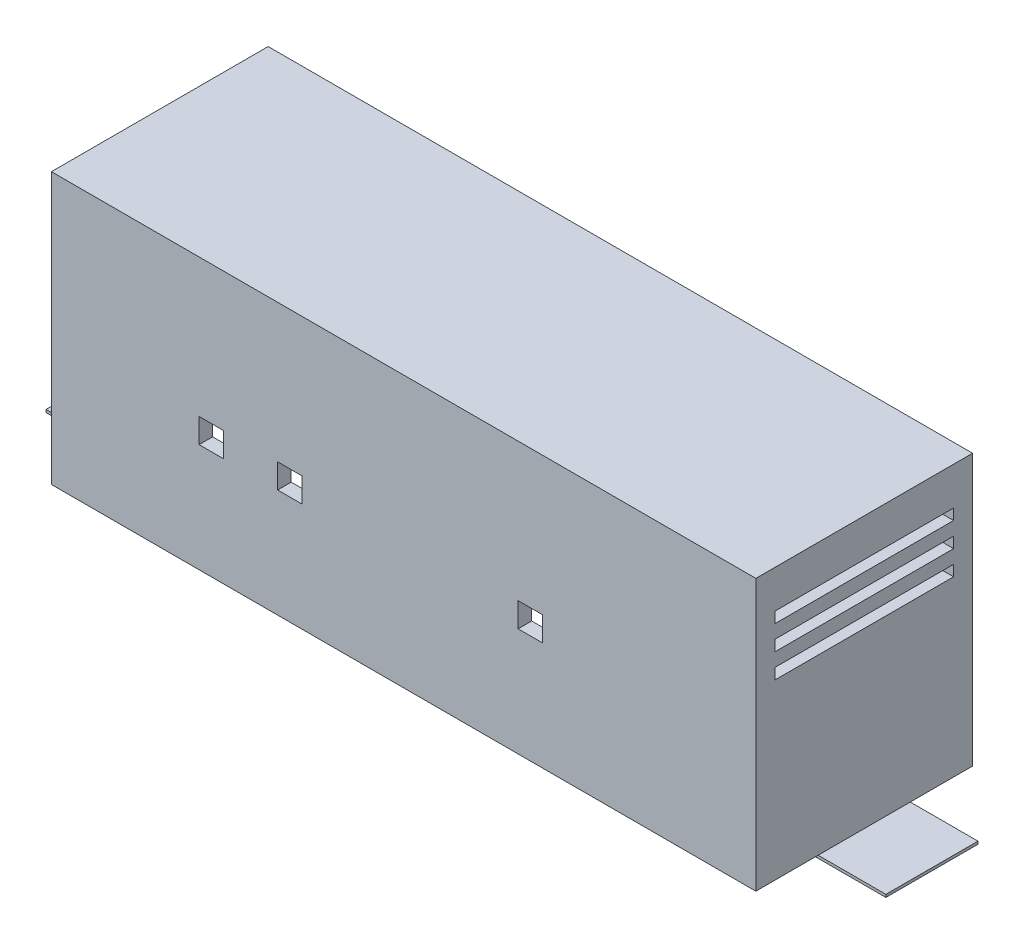
from build123d import *

# Parameters (mm, degrees)
SKETCH1_W                 = 260
SKETCH1_H                 = 80
BOSS_EXTRUDE1_DEPTH       = 100
SKETCH2_W                 = 250
SKETCH2_H                 = 70.000000188
INSIDE_DEPTH              = 90
SKETCH8_W                 = 9
SKETCH8_H                 = 9
WIRE_HOLES_DEPTH          = 23
SKETCH12_W                = 66
SKETCH12_H                = 4
VENTALATION_DEPTH         = 15
SKETCH14_W                = 66
SKETCH14_H                = 4
VENTALATION_2_DEPTH       = 10
SKETCH16_W                = 66
SKETCH16_H                = 4
VENTALATION_3_DEPTH       = 10
SKETCH20_W                = 34
SKETCH20_H                = 30
COMMAND_STRIP_FRONT_DEPTH = 1
SKETCH21_W                = 30
SKETCH21_H                = 34.000000188
COMMAND_STRIP_RIGHT_DEPTH = 1
SKETCH22_W                = 30
SKETCH22_H                = 34.000000188
BOSS_EXTRUDE4_DEPTH       = 1


with BuildPart() as part:
    # Sketch1 → Boss-Extrude1 (new body)
    with BuildSketch(Plane(origin=(0, 0, 0), x_dir=(1, 0, 0), z_dir=(0, 1, 0))):
        Rectangle(SKETCH1_W, SKETCH1_H)
    extrude(amount=BOSS_EXTRUDE1_DEPTH)

    # Sketch2 → inside (cut)
    with BuildSketch(Plane.XZ):
        Rectangle(SKETCH2_W, SKETCH2_H)
    extrude(amount=-INSIDE_DEPTH, mode=Mode.SUBTRACT)

    # Sketch8 → Wire holes (cut)
    with BuildSketch(Plane.XY.offset(40)):
        with Locations((-71, 44.5)):
            Rectangle(SKETCH8_W, SKETCH8_H)
        with Locations((-42, 44.5)):
            Rectangle(SKETCH8_W, SKETCH8_H)
        with Locations((46.75, 44.5)):
            Rectangle(SKETCH8_W, SKETCH8_H)
    extrude(amount=-WIRE_HOLES_DEPTH, mode=Mode.SUBTRACT)

    # Sketch12 → Ventalation (cut)
    with BuildSketch(Plane(origin=(130, 0, 0), x_dir=(0, 0, -1), z_dir=(1, 0, 0))):
        with Locations((0, 84)):
            Rectangle(SKETCH12_W, SKETCH12_H)
    extrude(amount=-VENTALATION_DEPTH, mode=Mode.SUBTRACT)

    # Sketch14 → Ventalation 2 (cut)
    with BuildSketch(Plane(origin=(130, 0, 0), x_dir=(0, 0, -1), z_dir=(1, 0, 0))):
        with Locations((0, 75)):
            Rectangle(SKETCH14_W, SKETCH14_H)
    extrude(amount=-VENTALATION_2_DEPTH, mode=Mode.SUBTRACT)

    # Sketch16 → Ventalation 3 (cut)
    with BuildSketch(Plane(origin=(130, 0, 0), x_dir=(0, 0, -1), z_dir=(1, 0, 0))):
        with Locations((0, 66)):
            Rectangle(SKETCH16_W, SKETCH16_H)
    extrude(amount=-VENTALATION_3_DEPTH, mode=Mode.SUBTRACT)

    # Sketch20 → Command Strip front (add)
    with BuildSketch(Plane.XZ):
        with Locations((0, -50.000000094)):
            Rectangle(SKETCH20_W, SKETCH20_H)
    extrude(amount=COMMAND_STRIP_FRONT_DEPTH)

    # Sketch21 → Command strip right (add)
    with BuildSketch(Plane.XZ):
        with Locations((-140, 0)):
            Rectangle(SKETCH21_W, SKETCH21_H)
    extrude(amount=COMMAND_STRIP_RIGHT_DEPTH)

    # Sketch22 → Boss-Extrude4 (add)
    with BuildSketch(Plane.XZ):
        with Locations((140, 0)):
            Rectangle(SKETCH22_W, SKETCH22_H)
    extrude(amount=BOSS_EXTRUDE4_DEPTH)


solid = part.part
